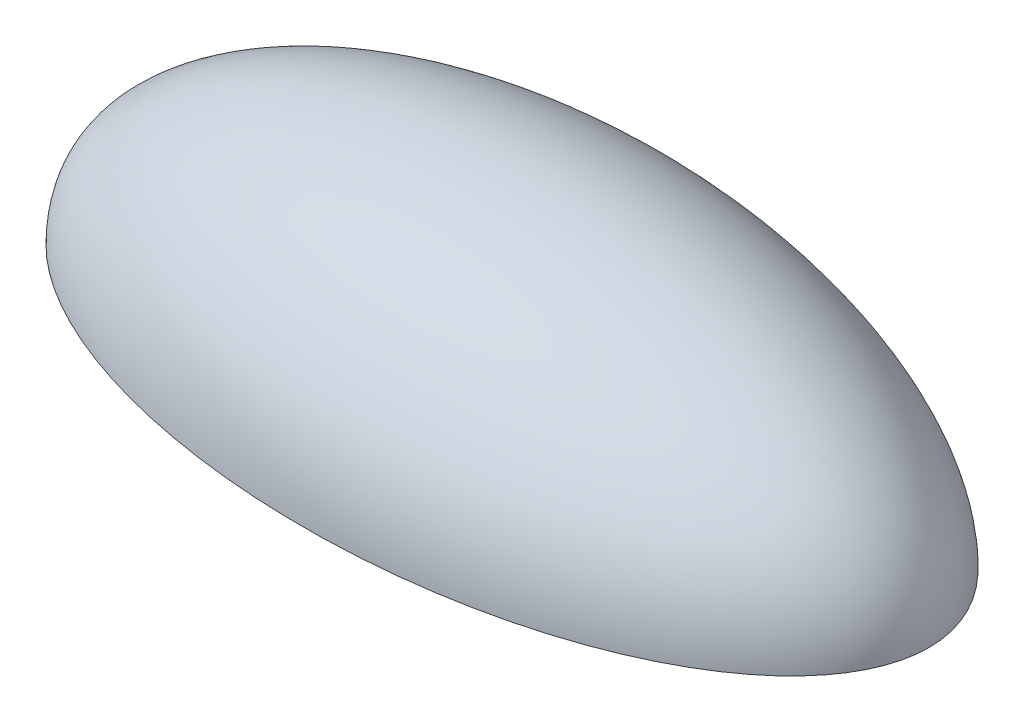
from build123d import *

# Parameters (mm, degrees)
REVOLVE3_ANGLE = 180


with BuildPart() as part:
    # Sketch1 → Revolve3 (revolve)
    with BuildSketch(Plane(origin=(0, 0, 0), x_dir=(1, 0, 0), z_dir=(0, 1, 0))):
        with BuildLine():
            Line((-12, 0), (12, 0))
            add(Edge.make_bspline(
                [(12, 0), (12, 6), (0, 6), (-12, 6), (-12, 0)],
                knots=[3.141592654, 3.141592654, 3.141592654, 4.71238898, 4.71238898, 6.283185307, 6.283185307, 6.283185307], degree=2, weights=[1, 0.707106781, 1, 0.707106781, 1]))
        make_face()
    revolve(axis=Axis((-12, 0, 0), (1, 0, 0)), revolution_arc=REVOLVE3_ANGLE)


solid = part.part
